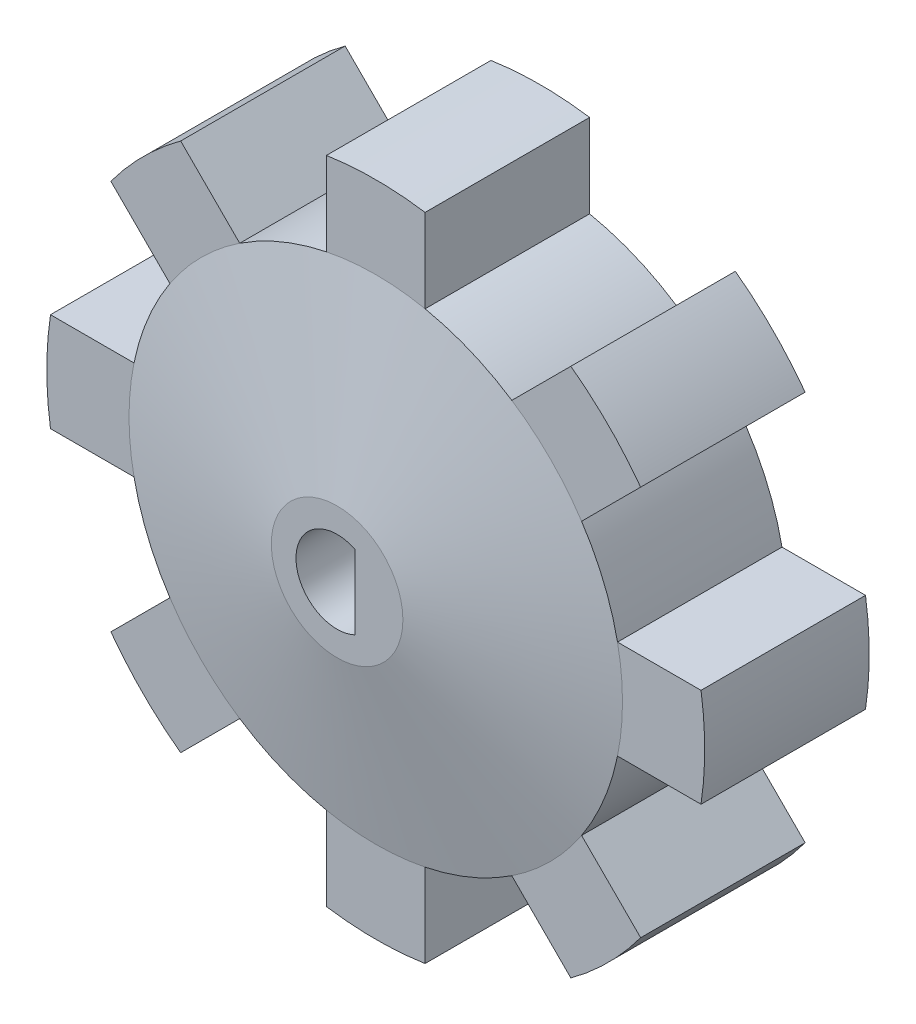
from build123d import *

# Parameters (mm, degrees)
SKETCH2_R          = 25
SKETCH2_R_2        = 20
CUT_EXTRUDE5_DEPTH = 30
CUT_EXTRUDE6_DEPTH = 20


with BuildPart() as part:
    # Sketch3 → Revolve3 (revolve)
    with BuildSketch(Plane(origin=(0, 0, 0), x_dir=(0, 0, -1), z_dir=(1, 0, 0)), mode=Mode.PRIVATE) as revolve3_sk:
        Polygon((0, 0), (14.7, 0), (14.7, 4), (12.35, 15), (12.35, 20), (2.35, 20), (2.35, 15), (0, 4), align=None)
    revolve(revolve3_sk.sketch.rotate(Axis((0, 0, 0), (0, 0, -1)), 90), axis=Axis((0, 0, 0), (0, 0, -1)))

    # Sketch2 → Cut-Extrude5 (cut)
    with BuildSketch(Plane.XY):
        Circle(SKETCH2_R)
        Circle(SKETCH2_R_2, mode=Mode.SUBTRACT)
        with BuildLine():
            ThreePointArc((-12.513625189, -8.270984502), (-13.858192988, -5.740251485), (-14.696938457, -3))
            Line((-14.696938457, -3), (-19.773719933, -3))
            ThreePointArc((-19.773719933, -3), (-18.47759065, -7.653668647), (-16.103451798, -11.860811111))
            Line((-16.103451798, -11.860811111), (-12.513625189, -8.270984502))
        make_face()
        with BuildLine():
            ThreePointArc((-14.696938457, 3), (-13.858192988, 5.740251485), (-12.513625189, 8.270984502))
            Line((-12.513625189, 8.270984502), (-16.103451798, 11.860811111))
            ThreePointArc((-16.103451798, 11.860811111), (-18.47759065, 7.653668647), (-19.773719933, 3))
            Line((-19.773719933, 3), (-14.696938457, 3))
        make_face()
        with BuildLine():
            ThreePointArc((-8.270984502, 12.513625189), (-5.740251485, 13.858192988), (-3, 14.696938457))
            Line((-3, 14.696938457), (-3, 19.773719933))
            ThreePointArc((-3, 19.773719933), (-7.653668647, 18.47759065), (-11.860811111, 16.103451798))
            Line((-11.860811111, 16.103451798), (-8.270984502, 12.513625189))
        make_face()
        with BuildLine():
            Line((3, 19.773719933), (3, 14.696938457))
            ThreePointArc((3, 14.696938457), (5.740251485, 13.858192988), (8.270984502, 12.513625189))
            Line((8.270984502, 12.513625189), (11.860811111, 16.103451798))
            ThreePointArc((11.860811111, 16.103451798), (7.653668647, 18.47759065), (3, 19.773719933))
        make_face()
        with BuildLine():
            Line((16.103451798, 11.860811111), (12.513625189, 8.270984502))
            ThreePointArc((12.513625189, 8.270984502), (13.858192988, 5.740251485), (14.696938457, 3))
            Line((14.696938457, 3), (19.773719933, 3))
            ThreePointArc((19.773719933, 3), (18.47759065, 7.653668647), (16.103451798, 11.860811111))
        make_face()
        with BuildLine():
            ThreePointArc((16.103451798, -11.860811111), (18.47759065, -7.653668647), (19.773719933, -3))
            Line((19.773719933, -3), (14.696938457, -3))
            ThreePointArc((14.696938457, -3), (13.858192988, -5.740251485), (12.513625189, -8.270984502))
            Line((12.513625189, -8.270984502), (16.103451798, -11.860811111))
        make_face()
        with BuildLine():
            ThreePointArc((3, -19.773719933), (7.653668647, -18.47759065), (11.860811111, -16.103451798))
            Line((11.860811111, -16.103451798), (8.270984502, -12.513625189))
            ThreePointArc((8.270984502, -12.513625189), (5.740251485, -13.858192988), (3, -14.696938457))
            Line((3, -14.696938457), (3, -19.773719933))
        make_face()
        with BuildLine():
            ThreePointArc((-3, -14.696938457), (-5.740251485, -13.858192988), (-8.270984502, -12.513625189))
            Line((-8.270984502, -12.513625189), (-11.860811111, -16.103451798))
            ThreePointArc((-11.860811111, -16.103451798), (-7.653668647, -18.47759065), (-3, -19.773719933))
            Line((-3, -19.773719933), (-3, -14.696938457))
        make_face()
    extrude(amount=-CUT_EXTRUDE5_DEPTH, mode=Mode.SUBTRACT)

    # Sketch4 → Cut-Extrude6 (cut)
    with BuildSketch(Plane.XY):
        with BuildLine():
            Line((1.089724736, -2.25), (1.089724736, 2.25))
            ThreePointArc((1.089724736, 2.25), (-2.5, 0), (1.089724736, -2.25))
        make_face()
    extrude(amount=-CUT_EXTRUDE6_DEPTH, mode=Mode.SUBTRACT)


solid = part.part
